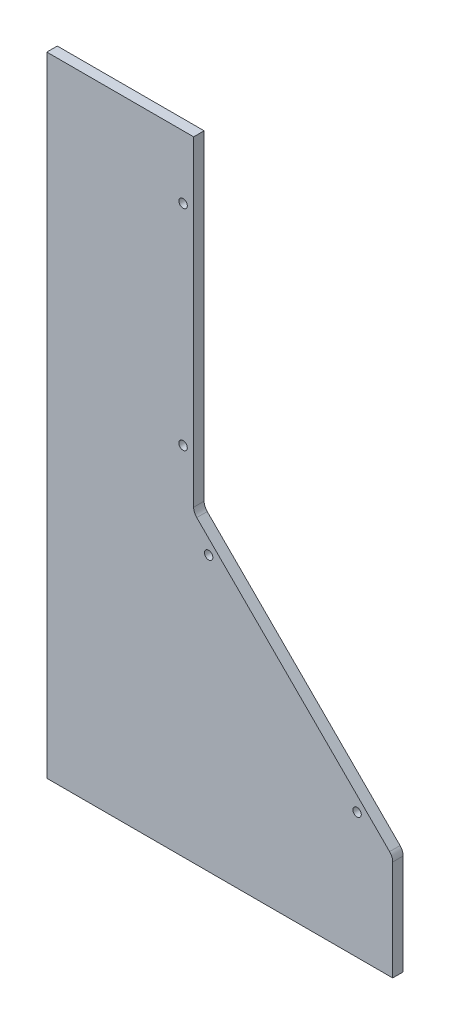
from build123d import *

# Parameters (mm, degrees)
BOSS_EXTRUDE1_DEPTH                                = 6.35
SKETCH2_W                                          = 33.274
SKETCH2_H                                          = 381
CUT_EXTRUDE1_DEPTH                                 = 7.35
CSK_FOR_10_FLAT_HEAD_MACHINE_SCREW_100_D           = 5.1054
CSK_FOR_10_FLAT_HEAD_MACHINE_SCREW_100_CSINK_D     = 9.779
CSK_FOR_10_FLAT_HEAD_MACHINE_SCREW_100_CSINK_ANGLE = 100


with BuildPart() as part:
    # Sketch1 → Boss-Extrude1 (new body)
    with BuildSketch(Plane.XY):
        with BuildLine():
            Line((141.422179454, -15.387658672), (141.422179454, -76.238562419))
            Line((141.422179454, -76.238562419), (133.548179454, -76.238562419))
            Line((133.548179454, -76.238562419), (-101.401820546, -76.238562419))
            Line((-101.401820546, -76.238562419), (-101.401820546, 304.761437581))
            Line((-101.401820546, 304.761437581), (0, 304.761437581))
            Line((0, 304.761437581), (20.828, 304.761437581))
            Line((20.828, 304.761437581), (20.828, 110.451437581))
            ThreePointArc((20.828, 110.451437581), (21.317531228, 108.006564216), (22.710647487, 105.938648918))
            Line((22.710647487, 105.938648918), (139.539531967, -10.874870008))
            ThreePointArc((139.539531967, -10.874870008), (140.932648226, -12.942785307), (141.422179454, -15.387658672))
        make_face()
    extrude(amount=BOSS_EXTRUDE1_DEPTH)

    # Sketch2 → Cut-Extrude1 (cut, through all)
    with BuildSketch(Plane.XY.offset(6.35)):
        with Locations((-84.764820546, 114.261437581)):
            Rectangle(SKETCH2_W, SKETCH2_H)
    extrude(amount=-CUT_EXTRUDE1_DEPTH, mode=Mode.SUBTRACT)

    # CSK for #10 Flat Head Machine Screw (100)1 (through all)
    with Locations(Plane(origin=(119.832179454, -0.038562419, 0), x_dir=(-1, 0, 0), z_dir=(0, 0, -1))):
        with Locations((0, 0), (89.916, 89.916), (105.41, 139.7), (105.41, 266.7)):
            CounterSinkHole(CSK_FOR_10_FLAT_HEAD_MACHINE_SCREW_100_D / 2, CSK_FOR_10_FLAT_HEAD_MACHINE_SCREW_100_CSINK_D / 2, counter_sink_angle=CSK_FOR_10_FLAT_HEAD_MACHINE_SCREW_100_CSINK_ANGLE)


solid = part.part
